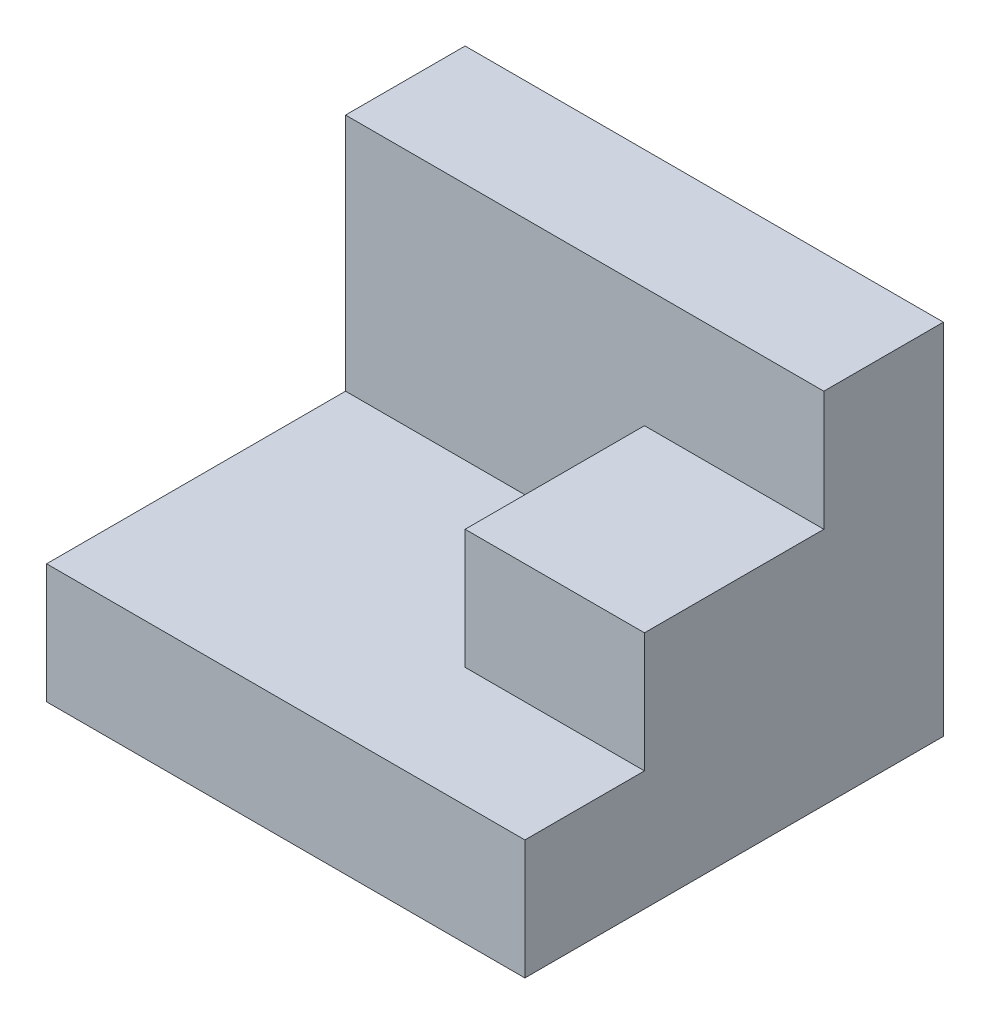
from build123d import *

# Parameters (mm, degrees)
BOSS_EXTRUDE1_DEPTH = 40
SKETCH2_W           = 15
SKETCH2_H           = 10
BOSS_EXTRUDE2_DEPTH = 15


with BuildPart() as part:
    # Sketch1 → Boss-Extrude1 (new body)
    with BuildSketch(Plane(origin=(0, 0, 0), x_dir=(0, 0, -1), z_dir=(1, 0, 0))):
        Polygon((10.105951264, 12.773109244), (10.105951264, -17.226890756), (-24.894048736, -17.226890756), (-24.894048736, -7.226890756), (0.105951264, -7.226890756), (0.105951264, 12.773109244), align=None)
    extrude(amount=-BOSS_EXTRUDE1_DEPTH)

    # Sketch2 → Boss-Extrude2 (add)
    with BuildSketch(Plane(origin=(0, 0, 0), x_dir=(0, 0, -1), z_dir=(1, 0, 0))):
        with Locations((-7.394048736, -2.226890756)):
            Rectangle(SKETCH2_W, SKETCH2_H)
    extrude(amount=-BOSS_EXTRUDE2_DEPTH)


solid = part.part
